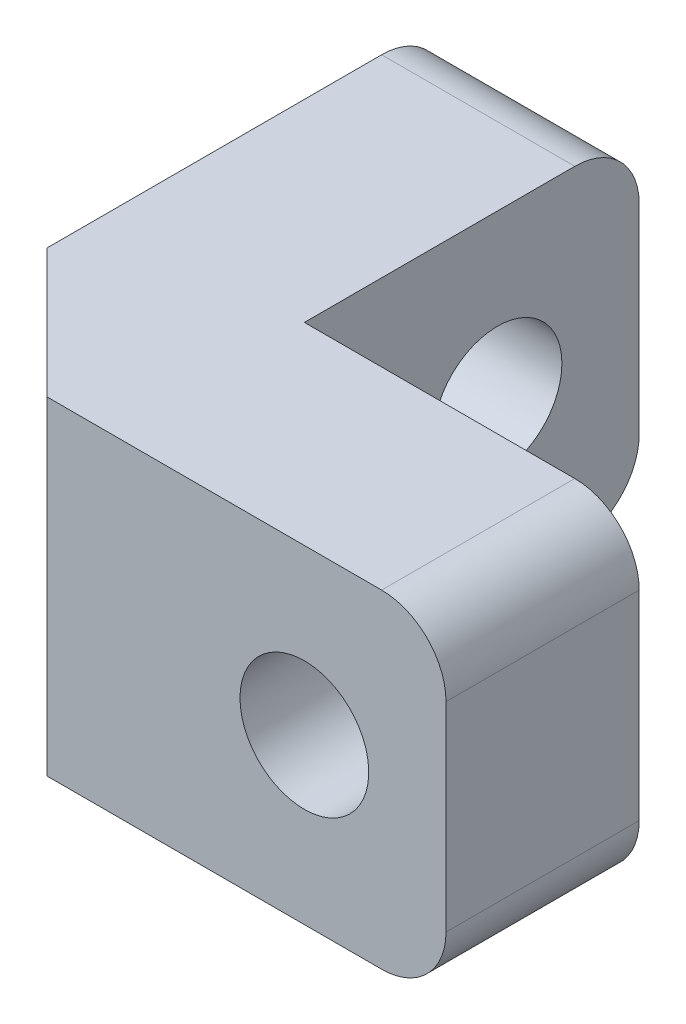
from build123d import *

# Parameters (mm, degrees)
BOSS_EXTRUDE1_DEPTH = 5.1
CHAMFER1_SIZE       = 2
FILLET1_R           = 1
SKETCH3_R           = 1
CUT_EXTRUDE1_DEPTH  = 5.1
SKETCH4_R           = 1
CUT_EXTRUDE2_DEPTH  = 5.1
SKETCH5_R           = 1.7
CUT_EXTRUDE3_DEPTH  = 1.4
SKETCH6_R           = 1.7
CUT_EXTRUDE4_DEPTH  = 1.4


with BuildPart() as part:
    # Sketch1 → Boss-Extrude1 (new body)
    with BuildSketch(Plane(origin=(0, 0, 0), x_dir=(1, 0, 0), z_dir=(0, 1, 0))):
        Polygon((0, 0), (0, 5.2), (-3, 5.2), (-3, -3), (5.2, -3), (5.2, 0), align=None)
    extrude(amount=BOSS_EXTRUDE1_DEPTH)

    # Chamfer1
    chamfer1_edges = [part.edges().sort_by_distance(p)[0] for p in [
        (-3, 2.55, 3),
    ]]
    chamfer(chamfer1_edges, length=CHAMFER1_SIZE)

    # Fillet1
    fillet1_edges = [part.edges().sort_by_distance(p)[0] for p in [
        (-1.5, 5.1, -5.2),
        (5.2, 5.1, 1.5),
        (5.2, 0, 1.5),
        (-1.5, 0, -5.2),
    ]]
    fillet(fillet1_edges, radius=FILLET1_R)

    # Sketch3 → Cut-Extrude1 (cut)
    with BuildSketch(Plane(origin=(0, 0, 0), x_dir=(0, 0, -1), z_dir=(1, 0, 0))):
        with Locations((3, 2.55)):
            Circle(SKETCH3_R)
    extrude(amount=-CUT_EXTRUDE1_DEPTH, mode=Mode.SUBTRACT)

    # Sketch4 → Cut-Extrude2 (cut)
    with BuildSketch(Plane(origin=(0, 0, 0), x_dir=(-1, 0, 0), z_dir=(0, 0, -1))):
        with Locations((-3, 2.55)):
            Circle(SKETCH4_R)
    extrude(amount=-CUT_EXTRUDE2_DEPTH, mode=Mode.SUBTRACT)

    # Sketch5 → Cut-Extrude3 (cut)
    with BuildSketch(Plane(origin=(0, 0, 0), x_dir=(-1, 0, 0), z_dir=(0, 0, -1))):
        with Locations((-3, 2.55)):
            Circle(SKETCH5_R)
    extrude(amount=-CUT_EXTRUDE3_DEPTH, mode=Mode.SUBTRACT)

    # Sketch6 → Cut-Extrude4 (cut)
    with BuildSketch(Plane.ZY.offset(3)):
        with Locations((-3, 2.55)):
            Circle(SKETCH6_R)
    extrude(amount=-CUT_EXTRUDE4_DEPTH, mode=Mode.SUBTRACT)


solid = part.part
